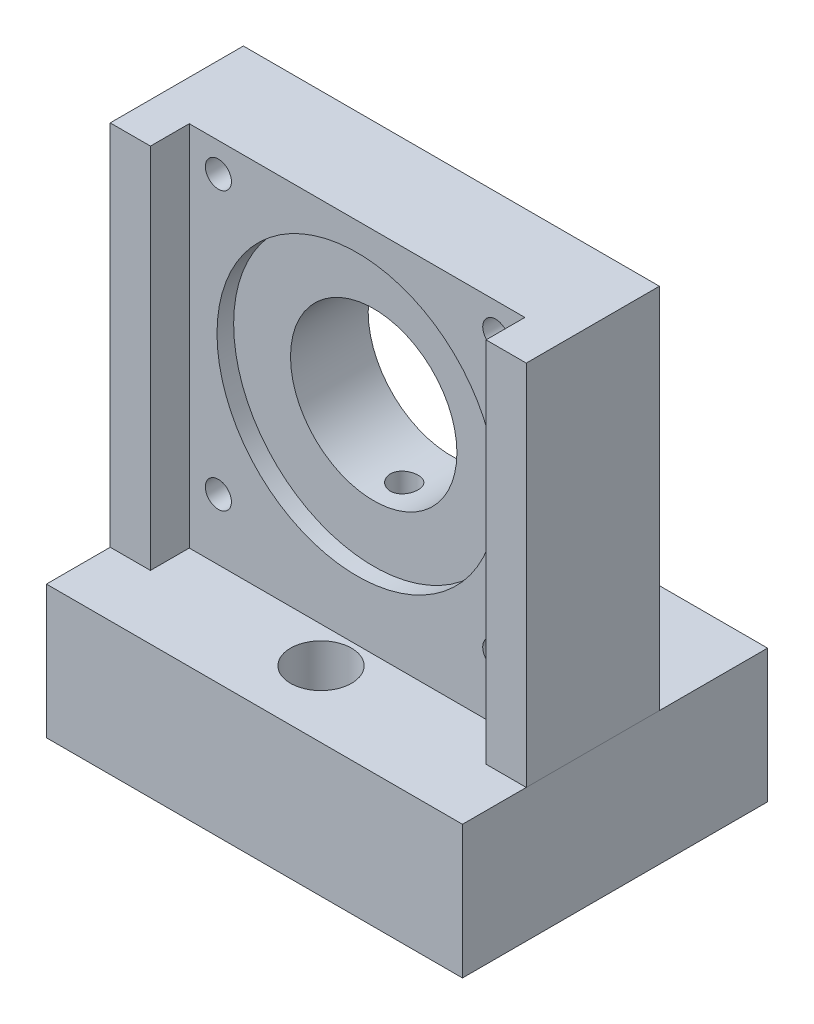
from build123d import *

# Parameters (mm, degrees)
SKETCH1_W              = 75
SKETCH1_H              = 72
BOSS_EXTRUDE1_DEPTH    = 12
SKETCH3_W              = 60.5
SKETCH3_H              = 60.5
CUT_EXTRUDE2_DEPTH     = 7
SKETCH2_R              = 25.25
CUT_EXTRUDE1_DEPTH     = 3
SKETCH4_R              = 15
CUT_EXTRUDE3_DEPTH     = 29
SKETCH5_W              = 75
SKETCH5_H              = 29.75
BOSS_EXTRUDE2_DEPTH    = 67
SKETCH6_W              = 75
SKETCH6_H              = 5.75
CUT_EXTRUDE4_DEPTH     = 67
SKETCH15_W             = 75
SKETCH15_H             = 55
CUT_EXTRUDE12_DEPTH    = 5.75
SKETCH7_R              = 3.2
CUT_EXTRUDE5_DEPTH     = 67
SKETCH9_OUTSIDE_W      = 112.624
SKETCH9_OUTSIDE_H      = 171.624
SKETCH9_OUTSIDE_W_2    = 75
SKETCH9_OUTSIDE_H_2    = 55
CUT_EXTRUDE7_DEPTH     = 102.411599435
SKETCH8_R              = 5.5
CUT_EXTRUDE6_DEPTH     = 13
SKETCH10_R             = 2.35
CUT_EXTRUDE8_DEPTH     = 80.614697136
SKETCH11_R             = 2.5
CUT_EXTRUDE9_DEPTH     = 54
SKETCH12_R             = 3.2
CUT_EXTRUDE10_DEPTH    = 24
SKETCH13_R             = 5.5
CUT_EXTRUDE11_DEPTH    = 15
SPLIT1_SURFACE_1_BACK  = 130.596
SPLIT1_SURFACE_1_DEPTH = 261.192
SPLIT1_SURFACE_2_BACK  = 130.596
SPLIT1_SURFACE_2_DEPTH = 261.192


with BuildPart() as part:
    # Sketch1 → Boss-Extrude1 (new, symmetric)
    with BuildSketch(Plane.XY):
        Rectangle(SKETCH1_W, SKETCH1_H)
    extrude(amount=BOSS_EXTRUDE1_DEPTH, both=True)

    # Sketch3 → Cut-Extrude2 (cut)
    with BuildSketch(Plane.XY.offset(12)):
        Rectangle(SKETCH3_W, SKETCH3_H)
    extrude(amount=-CUT_EXTRUDE2_DEPTH, mode=Mode.SUBTRACT)

    # Sketch2 → Cut-Extrude1 (cut)
    with BuildSketch(Plane.XY.offset(5)):
        Circle(SKETCH2_R)
    extrude(amount=-CUT_EXTRUDE1_DEPTH, mode=Mode.SUBTRACT)

    # Sketch4 → Cut-Extrude3 (cut)
    with BuildSketch(Plane.XY.offset(2)):
        Circle(SKETCH4_R)
    extrude(amount=-CUT_EXTRUDE3_DEPTH, mode=Mode.SUBTRACT)

    # Sketch5 → Boss-Extrude2 (add, symmetric)
    with BuildSketch(Plane.XY):
        with Locations((0, -45.125)):
            Rectangle(SKETCH5_W, SKETCH5_H)
    extrude(amount=BOSS_EXTRUDE2_DEPTH, both=True)

    # Sketch6 → Cut-Extrude4 (cut, symmetric)
    with BuildSketch(Plane.XY.offset(12)):
        with Locations((0, 33.125)):
            Rectangle(SKETCH6_W, SKETCH6_H)
    extrude(amount=CUT_EXTRUDE4_DEPTH, both=True, mode=Mode.SUBTRACT)

    # Sketch15 → Cut-Extrude12 (cut)
    with BuildSketch(Plane(origin=(0, -30.25, 0), x_dir=(1, 0, 0), z_dir=(0, 1, 0))):
        with Locations((0, 39.5)):
            Rectangle(SKETCH15_W, SKETCH15_H)
        Polygon((-30.25, -5), (-30.25, -12), (-37.5, -12), (-37.5, -67), (37.5, -67), (37.5, -12), (30.25, -12), (30.25, -5), align=None)
    extrude(amount=-CUT_EXTRUDE12_DEPTH, mode=Mode.SUBTRACT)

    # Sketch7 → Cut-Extrude5 (cut, symmetric)
    with BuildSketch(Plane(origin=(0, -36, 0), x_dir=(1, 0, 0), z_dir=(0, 1, 0))):
        with Locations(Location((-17.5, 19.5, 0), (0, 0, 180))):
            Circle(SKETCH7_R)
        with Locations(Location((0, -11.5, 0), (0, 0, 180))):
            Circle(SKETCH7_R)
        with Locations(Location((17.5, 19.5, 0), (0, 0, 180))):
            Circle(SKETCH7_R)
    extrude(amount=CUT_EXTRUDE5_DEPTH, both=True, mode=Mode.SUBTRACT)

    # Sketch9 outside → Cut-Extrude7 (cut, through all)
    with BuildSketch(Plane(origin=(0, -36, 0), x_dir=(1, 0, 0), z_dir=(0, 1, 0))):
        Rectangle(SKETCH9_OUTSIDE_W, SKETCH9_OUTSIDE_H)
        with Locations((0, 4)):
            Rectangle(SKETCH9_OUTSIDE_W_2, SKETCH9_OUTSIDE_H_2, mode=Mode.SUBTRACT)
    extrude(amount=-CUT_EXTRUDE7_DEPTH, mode=Mode.SUBTRACT)

    # Sketch8 → Cut-Extrude6 (cut)
    with BuildSketch(Plane(origin=(0, -36, 0), x_dir=(1, 0, 0), z_dir=(0, 1, 0))):
        with Locations(Location((-17.5, 19.5, 0), (0, 0, 180))):
            Circle(SKETCH8_R)
        with Locations(Location((17.5, 19.5, 0), (0, 0, 180))):
            Circle(SKETCH8_R)
        with Locations(Location((0, -11.5, 0), (0, 0, 180))):
            Circle(SKETCH8_R)
    extrude(amount=-CUT_EXTRUDE6_DEPTH, mode=Mode.SUBTRACT)

    # Sketch10 → Cut-Extrude8 (cut, through all)
    with BuildSketch(Plane.XY.offset(5)):
        with Locations((-25, 25)):
            Circle(SKETCH10_R)
        with Locations((25, 25)):
            Circle(SKETCH10_R)
        with Locations((25, -25)):
            Circle(SKETCH10_R)
        with Locations((-25, -25)):
            Circle(SKETCH10_R)
    extrude(amount=-CUT_EXTRUDE8_DEPTH, mode=Mode.SUBTRACT)

    # Sketch11 → Cut-Extrude9 (cut)
    with BuildSketch(Plane.XZ.offset(60)):
        with Locations((-19, -3.5)):
            Circle(SKETCH11_R)
        with Locations(Location((19, -3.5, 0), (0, 0, 180))):
            Circle(SKETCH11_R)
        with Locations((0, -3.5)):
            Circle(SKETCH11_R)
    extrude(amount=-CUT_EXTRUDE9_DEPTH, mode=Mode.SUBTRACT)

    # Sketch12 → Cut-Extrude10 (cut)
    with BuildSketch(Plane.XZ.offset(60)):
        with Locations((-19, -3.5)):
            Circle(SKETCH12_R)
        with Locations((0, -3.5)):
            Circle(SKETCH12_R)
        with Locations((19, -3.5)):
            Circle(SKETCH12_R)
    extrude(amount=-CUT_EXTRUDE10_DEPTH, mode=Mode.SUBTRACT)

    # Sketch13 → Cut-Extrude11 (cut)
    with BuildSketch(Plane.XZ.offset(60)):
        with Locations((-19, -3.5)):
            Circle(SKETCH13_R)
        with Locations((0, -3.5)):
            Circle(SKETCH13_R)
        with Locations((19, -3.5)):
            Circle(SKETCH13_R)
    extrude(amount=-CUT_EXTRUDE11_DEPTH, mode=Mode.SUBTRACT)


with BuildPart() as body_2:
    # Split1: the piece behind the surface
    add(part.part)
    # Split1 surface: a surface, the sketch's curves swept straight by 261.192 mm
    with BuildLine(Plane(origin=(37.5, 0, 0), x_dir=(0, 0, -1), z_dir=(1, 0, 0)).offset(-SPLIT1_SURFACE_1_BACK), mode=Mode.PRIVATE) as split1_surface_1_path:
        Line((-23.5, -36), (31.5, -36))
    split1_surface_1 = Shell.extrude(split1_surface_1_path.wire(), (1 * SPLIT1_SURFACE_1_DEPTH, 0 * SPLIT1_SURFACE_1_DEPTH, 0 * SPLIT1_SURFACE_1_DEPTH))
    split(bisect_by=split1_surface_1, keep=Keep.BOTTOM)


with BuildPart() as part_1:
    add(part.part)

    # Split1: split by a surface, the side it looks to stays
    # Split1 surface: a surface, the sketch's curves swept straight by 261.192 mm
    with BuildLine(Plane(origin=(37.5, 0, 0), x_dir=(0, 0, -1), z_dir=(1, 0, 0)).offset(-SPLIT1_SURFACE_2_BACK), mode=Mode.PRIVATE) as split1_surface_2_path:
        Line((-23.5, -36), (31.5, -36))
    split1_surface_2 = Shell.extrude(split1_surface_2_path.wire(), (1 * SPLIT1_SURFACE_2_DEPTH, 0 * SPLIT1_SURFACE_2_DEPTH, 0 * SPLIT1_SURFACE_2_DEPTH))
    split(bisect_by=split1_surface_2, keep=Keep.TOP)


solid = Compound([body_2.part, part_1.part])
